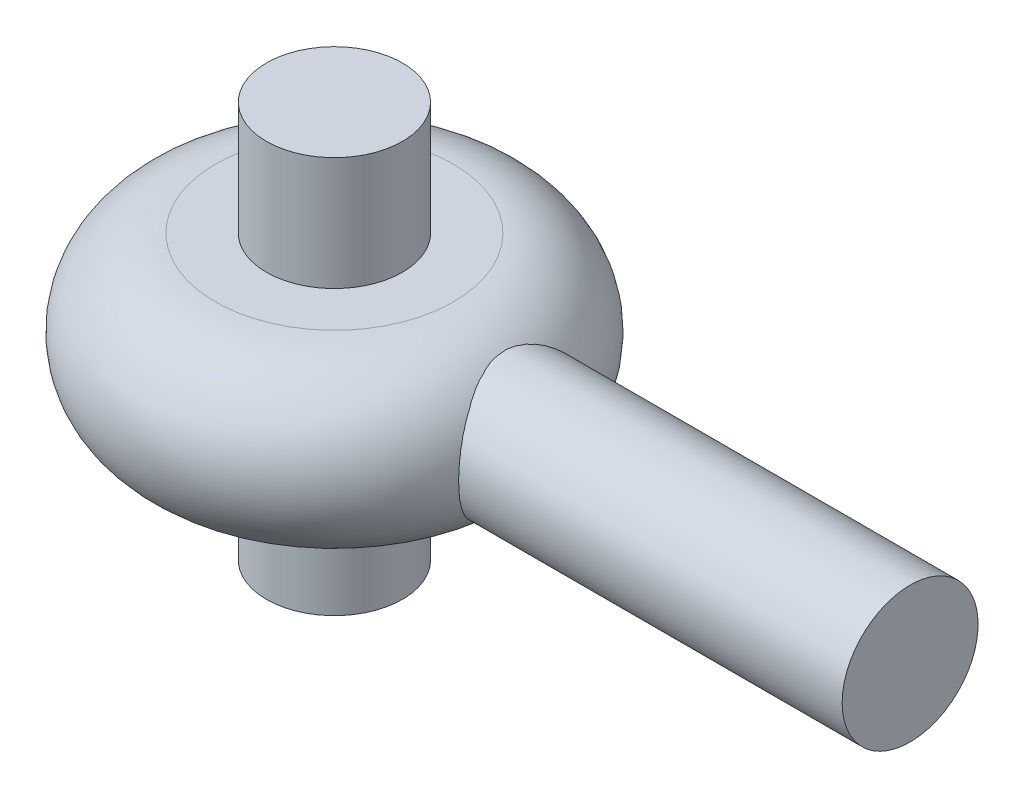
from build123d import *

# Parameters (mm, degrees)
SKETCH14_R                 = 6
SOLIDPROFILES_12MM_1_DEPTH = 40.783715088
SKETCH15_R                 = 6
BOSS_EXTRUDE1_DEPTH        = 10
BOSS_EXTRUDE1_DEPTH_BACK   = 25


with BuildPart() as part:
    # Sketch3 → Revolve2 (revolve)
    with BuildSketch(Plane(origin=(0, 0, 0), x_dir=(0, 0, -1), z_dir=(1, 0, 0))):
        with BuildLine():
            Line((6, 7.5), (10.516501258, 7.5))
            ThreePointArc((10.516501258, 7.5), (18.016501258, 0), (10.516501258, -7.5))
            Line((10.516501258, -7.5), (6, -7.5))
            Line((6, -7.5), (6, 7.5))
        make_face()
    revolve(axis=Axis((0, 0, 0), (0, 1, 0)))


with BuildPart() as body_2:
    # Sketch14 → Solidprofiles 12MM(1) (new body)
    with BuildSketch(Plane.ZY.offset(-50.8)):
        Circle(SKETCH14_R)
    extrude(amount=SOLIDPROFILES_12MM_1_DEPTH)


with BuildPart() as body_3:
    # Sketch15 → Boss-Extrude1 (new, two sides)
    with BuildSketch(Plane(origin=(0, 7.5, 0), x_dir=(1, 0, 0), z_dir=(0, 1, 0))) as boss_extrude1_sk:
        with Locations(Location((0, 0, 0), (0, 0, 270))):
            Circle(SKETCH15_R)
    extrude(amount=BOSS_EXTRUDE1_DEPTH)
    extrude(boss_extrude1_sk.sketch, amount=-BOSS_EXTRUDE1_DEPTH_BACK)


solid = Compound([part.part, body_2.part, body_3.part])
